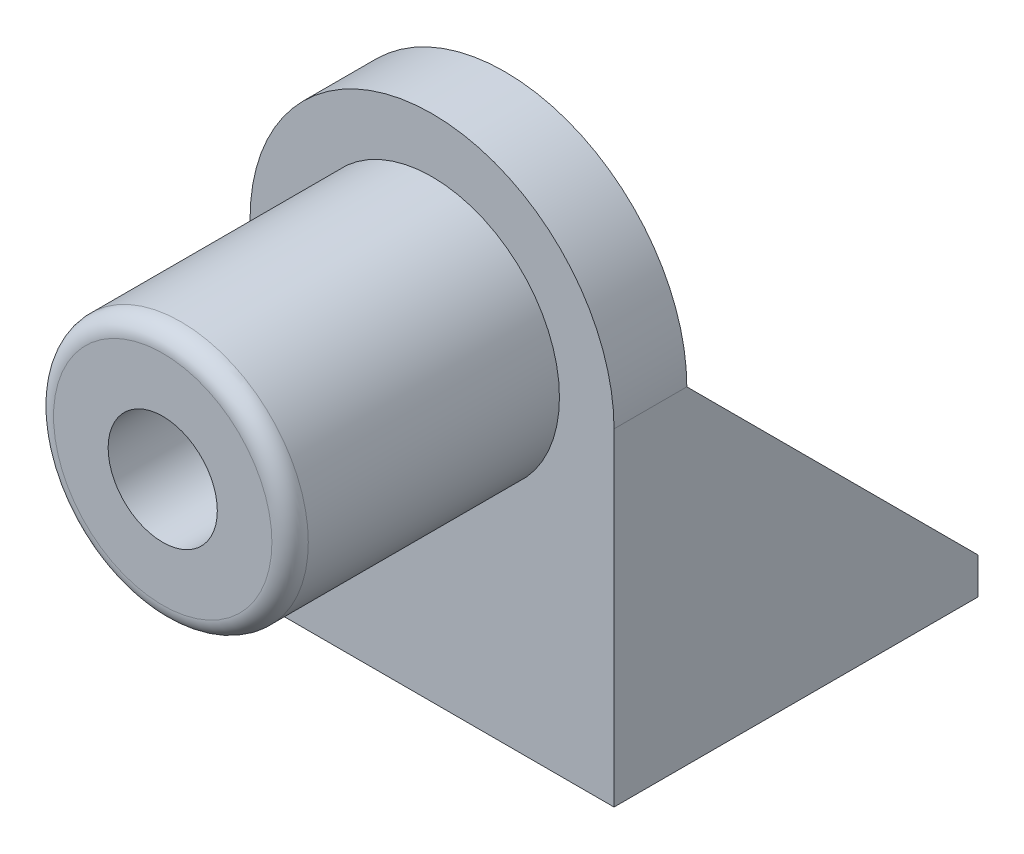
from build123d import *

# Parameters (mm, degrees)
SKETCH1_R           = 11.1125
SKETCH1_R_2         = 4.7625
BOSS_EXTRUDE1_DEPTH = 23.495
SKETCH2_R           = 4.7625
BOSS_EXTRUDE2_DEPTH = 6.35
SKETCH3_W           = 31.75
SKETCH3_H           = 3.175
BOSS_EXTRUDE3_DEPTH = 25.4
BOSS_EXTRUDE4_DEPTH = 3.175
BOSS_EXTRUDE5_DEPTH = 3.175
SKETCH6_R           = 1.5
CUT_EXTRUDE1_DEPTH  = 12.319
FILLET1_R           = 1.5875


with BuildPart() as part:
    # Sketch1 → Boss-Extrude1 (new body)
    with BuildSketch(Plane.XY):
        Circle(SKETCH1_R)
        Circle(SKETCH1_R_2, mode=Mode.SUBTRACT)
    extrude(amount=BOSS_EXTRUDE1_DEPTH)

    # Sketch2 → Boss-Extrude2 (add)
    with BuildSketch(Plane(origin=(0, 0, 0), x_dir=(-1, 0, 0), z_dir=(0, 0, -1))):
        with BuildLine():
            Line((15.875, -28.575), (15.875, 0))
            ThreePointArc((15.875, 0), (0, 15.875), (-15.875, 0))
            Line((-15.875, 0), (-15.875, -28.575))
            Line((-15.875, -28.575), (15.875, -28.575))
        make_face()
        Circle(SKETCH2_R, mode=Mode.SUBTRACT)
    extrude(amount=BOSS_EXTRUDE2_DEPTH)

    # Sketch3 → Boss-Extrude3 (add)
    with BuildSketch(Plane(origin=(0, 0, -6.35), x_dir=(-1, 0, 0), z_dir=(0, 0, -1))):
        with Locations((0, -26.9875)):
            Rectangle(SKETCH3_W, SKETCH3_H)
    extrude(amount=BOSS_EXTRUDE3_DEPTH)

    # Sketch4 → Boss-Extrude4 (add)
    with BuildSketch(Plane.ZY.offset(15.875)):
        Polygon((-31.75, -25.4), (-6.35, 0), (-6.35, -25.4), align=None)
    extrude(amount=-BOSS_EXTRUDE4_DEPTH)

    # Sketch5 → Boss-Extrude5 (add)
    with BuildSketch(Plane(origin=(15.875, 0, 0), x_dir=(0, 0, -1), z_dir=(1, 0, 0))):
        Polygon((6.35, -25.4), (31.75, -25.4), (6.35, 0), align=None)
    extrude(amount=-BOSS_EXTRUDE5_DEPTH)

    # Sketch6 → Cut-Extrude1 (cut)
    with BuildSketch(Plane(origin=(0, -25.4, 0), x_dir=(1, 0, 0), z_dir=(0, 1, 0))):
        with Locations((-9.525, 28.575)):
            Circle(SKETCH6_R)
        with Locations((9.525, 28.575)):
            Circle(SKETCH6_R)
        with Locations((9.525, 9.525)):
            Circle(SKETCH6_R)
        with Locations((-9.525, 9.525)):
            Circle(SKETCH6_R)
    extrude(amount=-CUT_EXTRUDE1_DEPTH, mode=Mode.SUBTRACT)

    # Fillet1
    fillet1_edges = [part.edges().sort_by_distance(p)[0] for p in [
        (-11.1125, 0, 23.495),
    ]]
    fillet(fillet1_edges, radius=FILLET1_R)


solid = part.part
